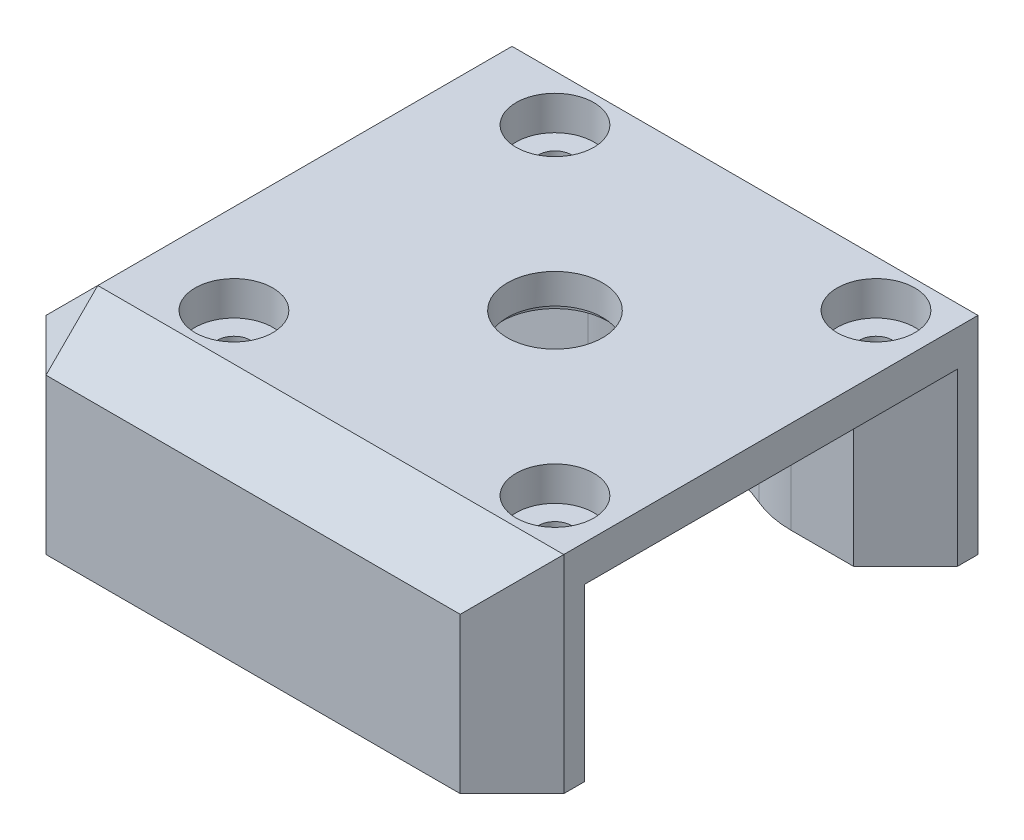
from build123d import *

# Parameters (mm, degrees)
SKETCH_1_W          = 50
SKETCH_1_H          = 50
SKETCH_1_R          = 1.6
EXTRUDE_1_DEPTH     = 20
SKETCH_2_W          = 45
SKETCH_2_H          = 26
CUT_EXTRUDE_1_DEPTH = 16.5
SKETCH_4_R          = 4.6
CUT_EXTRUDE_2_DEPTH = 15
SKETCH_5_R          = 5.15
CUT_EXTRUDE_3_DEPTH = 0.6
CHAMFER_1_SIZE      = 5
SKETCH_6_R          = 3.75
CUT_EXTRUDE_4_DEPTH = 3.3
SKETCH_7_R          = 15
CUT_EXTRUDE_5_DEPTH = 16.5
FILLET_1_R          = 10


with BuildPart() as part:
    # 草图1 → 凸台-拉伸1 (new body)
    with BuildSketch(Plane(origin=(0, 0, 0), x_dir=(1, 0, 0), z_dir=(0, 1, 0))):
        with Locations((25, 25)):
            Rectangle(SKETCH_1_W, SKETCH_1_H)
        with Locations((13.65, 40.5)):
            Circle(SKETCH_1_R, mode=Mode.SUBTRACT)
        with Locations((44.65, 40.5)):
            Circle(SKETCH_1_R, mode=Mode.SUBTRACT)
        with Locations((44.65, 9.5)):
            Circle(SKETCH_1_R, mode=Mode.SUBTRACT)
        with Locations((13.65, 9.5)):
            Circle(SKETCH_1_R, mode=Mode.SUBTRACT)
    extrude(amount=EXTRUDE_1_DEPTH)

    # 草图2 → 切除-拉伸1 (cut)
    with BuildSketch(Plane.XZ):
        with Locations((27.5, -25)):
            Rectangle(SKETCH_2_W, SKETCH_2_H)
    extrude(amount=-CUT_EXTRUDE_1_DEPTH, mode=Mode.SUBTRACT)

    # 草图4 → 切除-拉伸2 (cut)
    with BuildSketch(Plane(origin=(0, 20, 0), x_dir=(1, 0, 0), z_dir=(0, 1, 0))):
        with Locations((29.15, 25)):
            Circle(SKETCH_4_R)
    extrude(amount=-CUT_EXTRUDE_2_DEPTH, mode=Mode.SUBTRACT)

    # 草图5 → 切除-拉伸3 (cut)
    with BuildSketch(Plane.XZ.offset(-16.5)):
        with Locations((29.15, -25)):
            Circle(SKETCH_5_R)
    extrude(amount=-CUT_EXTRUDE_3_DEPTH, mode=Mode.SUBTRACT)

    # 倒角1
    chamfer_1_edges = [part.edges().sort_by_distance(p)[0] for p in [
        (25, 20, -50),
        (50, 8.25, -12),
        (50, 8.25, -38),
        (0, 20, -25),
        (0, 10, -50),
        (50, 10, -50),
        (50, 10, 0),
        (0, 10, 0),
        (25, 20, 0),
    ]]
    chamfer(chamfer_1_edges, length=CHAMFER_1_SIZE)

    # 草图6 → 切除-拉伸4 (cut)
    with BuildSketch(Plane(origin=(0, 20, 0), x_dir=(1, 0, 0), z_dir=(0, 1, 0))):
        with Locations((13.65, 40.5)):
            Circle(SKETCH_6_R)
        with Locations((44.65, 40.5)):
            Circle(SKETCH_6_R)
        with Locations((44.65, 9.5)):
            Circle(SKETCH_6_R)
        with Locations((13.65, 9.5)):
            Circle(SKETCH_6_R)
    extrude(amount=-CUT_EXTRUDE_4_DEPTH, mode=Mode.SUBTRACT)

    # 草图7 → 切除-拉伸5 (cut)
    with BuildSketch(Plane.XZ):
        with Locations((29.15, -25)):
            Circle(SKETCH_7_R)
    extrude(amount=-CUT_EXTRUDE_5_DEPTH, mode=Mode.SUBTRACT)

    # 圆角1
    fillet_1_edges = [part.edges().sort_by_distance(p)[0] for p in [
        (21.666685226, 8.25, -12),
        (36.633314774, 8.25, -12),
        (36.633314774, 8.25, -38),
        (21.666685226, 8.25, -38),
    ]]
    fillet(fillet_1_edges, radius=FILLET_1_R)


solid = part.part
